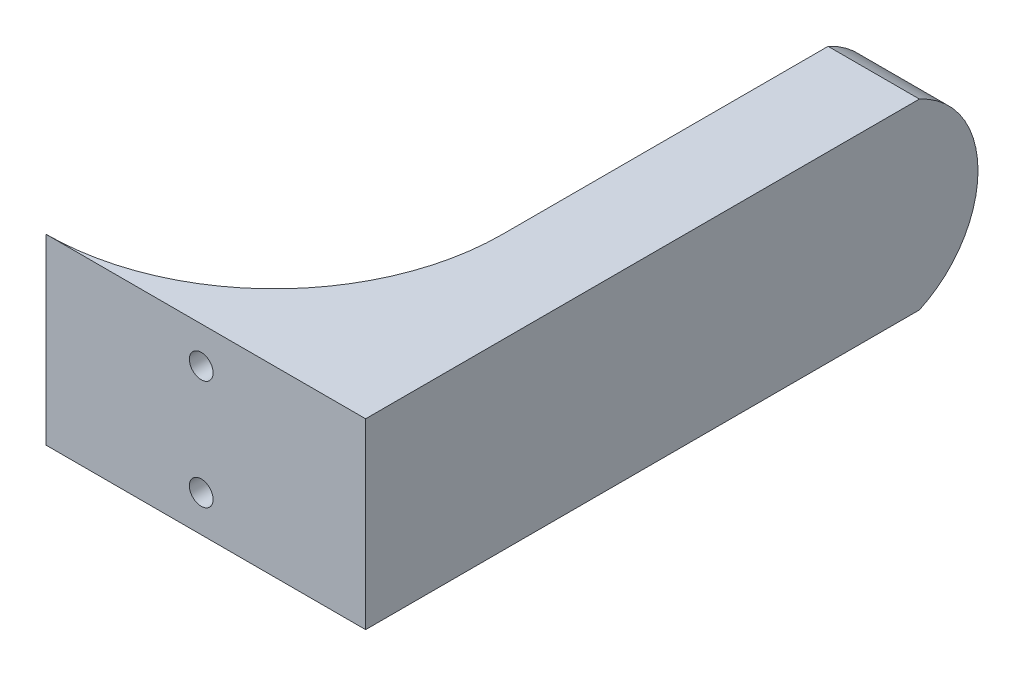
from build123d import *

# Parameters (mm, degrees)
BOSS_EXTRUDE1_DEPTH     = 25.4
SKETCH4_R               = 3.302
CUT_EXTRUDE2_DEPTH      = 7.62
SKETCH2_R               = 1.5875
SKETCH2_R_2             = 3.302
CUT_EXTRUDE3_DEPTH      = 7.62
SKETCH6_W               = 121.92
SKETCH6_H               = 12.7
BOSS_EXTRUDE2_DEPTH     = 7.62
CUT_EXTRUDE4_DEPTH      = 3.81
SKETCH10_R              = 2.921
CUT_EXTRUDE5_DEPTH      = 3.048
SKETCH11_R              = 1.5875
CUT_EXTRUDE6_DEPTH      = 96.25
CUT_EXTRUDE7_REACH      = 101.06
SKETCH12_W              = 8.89
SKETCH12_H              = 20.32
CUT_EXTRUDE8_DEPTH      = 1
CUT_EXTRUDE8_DEPTH_BACK = 122.92
CUT_EXTRUDE9_DEPTH      = 86.163777405
SKETCH16_W              = 44.941172762
SKETCH16_H              = 85.163777405
CUT_EXTRUDE10_DEPTH     = 51.8
SKETCH18_R              = 4.468004781
SKETCH18_R_2            = 4.110212911
BOSS_EXTRUDE3_DEPTH     = 2.54
SKETCH19_R              = 1.651
CUT_EXTRUDE11_DEPTH     = 2.54


with BuildPart() as part:
    # Sketch1 → Boss-Extrude1 (new body)
    with BuildSketch(Plane(origin=(0, 0, 0), x_dir=(1, 0, 0), z_dir=(0, 1, 0))):
        with BuildLine():
            Line((0, 0), (0, -59.69))
            ThreePointArc((0, -59.69), (9.299359697, -82.140640303), (31.75, -91.44))
            Line((31.75, -91.44), (69.85, -91.44))
            ThreePointArc((69.85, -91.44), (92.300640303, -82.140640303), (101.6, -59.69))
            Line((101.6, -59.69), (101.6, 0))
            Line((101.6, 0), (114.3, 0))
            Line((114.3, 0), (114.3, -99.06))
            Line((114.3, -99.06), (-7.62, -99.06))
            Line((-7.62, -99.06), (-7.62, 0))
            Line((-7.62, 0), (0, 0))
        make_face()
    extrude(amount=BOSS_EXTRUDE1_DEPTH)

    # Sketch4 → Cut-Extrude2 (cut)
    with BuildSketch(Plane.ZY.offset(-101.6)):
        with Locations((30.48, 12.7)):
            Circle(SKETCH4_R)
    extrude(amount=-CUT_EXTRUDE2_DEPTH, mode=Mode.SUBTRACT)

    # Sketch2 → Cut-Extrude3 (cut)
    with BuildSketch(Plane(origin=(0, 0, 0), x_dir=(0, 0, -1), z_dir=(1, 0, 0))):
        with Locations((-15.24, 12.7)):
            Circle(SKETCH2_R)
        with Locations((-45.72, 12.7)):
            Circle(SKETCH2_R)
        with Locations((-30.48, 12.7)):
            Circle(SKETCH2_R_2)
    extrude(amount=-CUT_EXTRUDE3_DEPTH, mode=Mode.SUBTRACT)

    # Sketch6 → Boss-Extrude2 (add)
    with BuildSketch(Plane.XY.offset(99.06)):
        with Locations((53.34, 31.75)):
            Rectangle(SKETCH6_W, SKETCH6_H)
        with Locations((53.34, -6.35)):
            Rectangle(SKETCH6_W, SKETCH6_H)
    extrude(amount=-BOSS_EXTRUDE2_DEPTH)

    # Sketch7 → Cut-Extrude4 (cut)
    with BuildSketch(Plane.XY.offset(99.06)):
        Polygon((12.284426472, 29.21), (9.901413236, 33.3375), (5.135386764, 33.3375), (2.752373528, 29.21), (5.135386764, 25.0825), (9.901413236, 25.0825), align=None)
        Polygon((103.724426472, -3.81), (101.341413236, 0.3175), (96.575386764, 0.3175), (94.192373528, -3.81), (96.575386764, -7.9375), (101.341413236, -7.9375), align=None)
    extrude(amount=-CUT_EXTRUDE4_DEPTH, mode=Mode.SUBTRACT)

    # Sketch10 → Cut-Extrude5 (cut)
    with BuildSketch(Plane.ZY.offset(7.62)):
        with Locations((15.24, 12.7)):
            Circle(SKETCH10_R)
        with Locations((45.72, 12.7)):
            Circle(SKETCH10_R)
    extrude(amount=-CUT_EXTRUDE5_DEPTH, mode=Mode.SUBTRACT)

    # Sketch11 → Cut-Extrude6 (cut, through all)
    with BuildSketch(Plane.XY.offset(95.25)):
        with Locations((7.5184, 29.21)):
            Circle(SKETCH11_R)
        with Locations((98.9584, -3.81)):
            Circle(SKETCH11_R)
    extrude(amount=-CUT_EXTRUDE6_DEPTH, mode=Mode.SUBTRACT)

    # Sketch12 → Cut-Extrude7 (cut, up to next)
    with BuildSketch(Plane.XY.offset(99.06), mode=Mode.PRIVATE) as cut_extrude7_sk1:
        with Locations((62.8396, 12.7)):
            Rectangle(SKETCH12_W, SKETCH12_H)
    cut_extrude7_tool1 = extrude(cut_extrude7_sk1.sketch, amount=-CUT_EXTRUDE7_REACH, mode=Mode.PRIVATE) & part.part
    add(cut_extrude7_tool1.solids().sort_by_distance((62.8396, 12.7, 99.06))[0], mode=Mode.SUBTRACT)

    # Sketch14 → Cut-Extrude8 (cut, two sides)
    with BuildSketch(Plane.ZY.offset(7.62)) as cut_extrude8_sk:
        with BuildLine():
            Line((14.426351463, 25.4), (0, 25.4))
            Line((0, 25.4), (0, 0))
            Line((0, 0), (14.426351463, 0))
            ThreePointArc((14.426351463, 0), (6.276222595, 12.7), (14.426351463, 25.4))
        make_face()
    extrude(amount=CUT_EXTRUDE8_DEPTH, mode=Mode.SUBTRACT)
    extrude(cut_extrude8_sk.sketch, amount=-CUT_EXTRUDE8_DEPTH_BACK, mode=Mode.SUBTRACT)

    # Sketch15 → Cut-Extrude9 (cut, through all)
    with BuildSketch(Plane(origin=(0, 0, 91.44), x_dir=(-1, 0, 0), z_dir=(0, 0, -1))):
        Polygon((-88.140443212, 20.32), (-89.790221606, 23.1775), (-93.089778394, 23.1775), (-94.739556788, 20.32), (-93.089778394, 17.4625), (-89.790221606, 17.4625), align=None)
        Polygon((-88.140443212, 5.08), (-89.790221606, 7.9375), (-93.089778394, 7.9375), (-94.739556788, 5.08), (-93.089778394, 2.2225), (-89.790221606, 2.2225), align=None)
    extrude(amount=CUT_EXTRUDE9_DEPTH, mode=Mode.SUBTRACT)

    # Sketch16 → Cut-Extrude10 (cut, through all)
    with BuildSketch(Plane(origin=(0, 38.1, 0), x_dir=(1, 0, 0), z_dir=(0, 1, 0))):
        Polygon((114.3, -99.06), (114.3, -91.44), (37.321172762, -91.44), (-7.62, -91.44), (-7.62, -99.06), align=None)
        with Locations((14.850586381, -48.858111298)):
            Rectangle(SKETCH16_W, SKETCH16_H)
    extrude(amount=-CUT_EXTRUDE10_DEPTH, mode=Mode.SUBTRACT)

    # Sketch18 → Boss-Extrude3 (add)
    with BuildSketch(Plane.XY.offset(91.44)):
        with Locations((91.226718038, 20.521889117)):
            Circle(SKETCH18_R)
        with Locations((91.757737736, 5.016113912)):
            Circle(SKETCH18_R_2)
    extrude(amount=-BOSS_EXTRUDE3_DEPTH)

    # Sketch19 → Cut-Extrude11 (cut)
    with BuildSketch(Plane.XY.offset(91.44)):
        with Locations((91.44, 20.32)):
            Circle(SKETCH19_R)
        with Locations((91.44, 5.08)):
            Circle(SKETCH19_R)
    extrude(amount=-CUT_EXTRUDE11_DEPTH, mode=Mode.SUBTRACT)


solid = part.part
